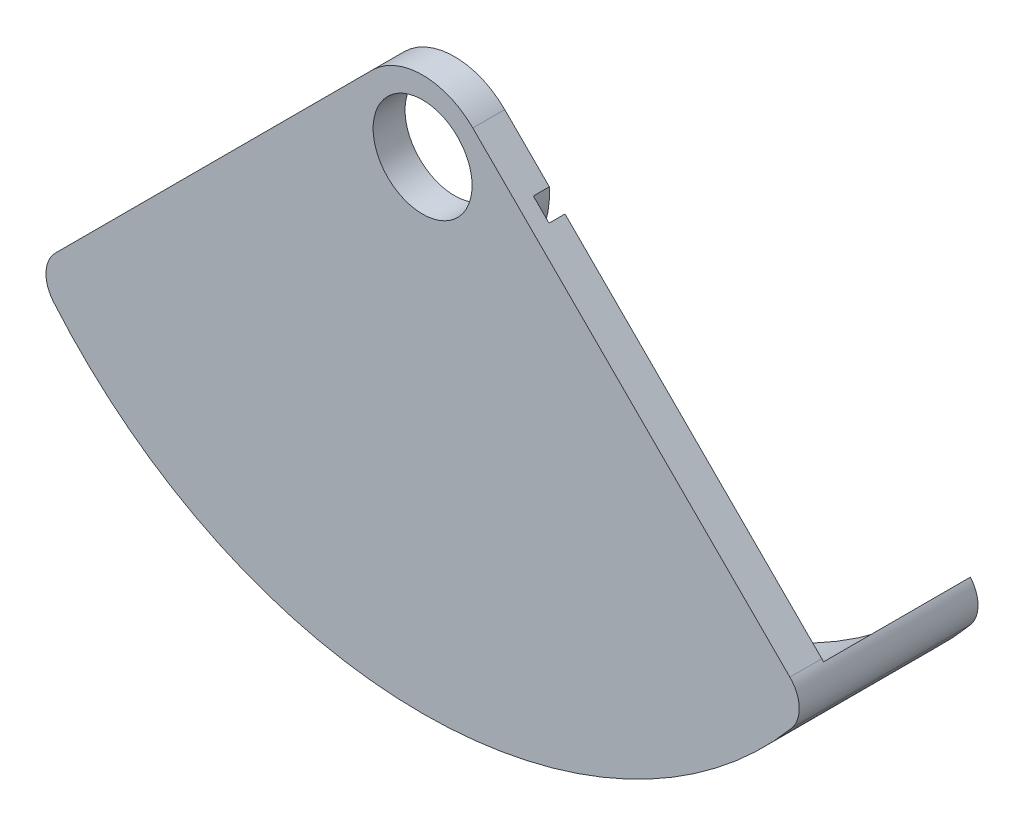
from build123d import *

# Parameters (mm, degrees)
CROQUIS1_R              = 1.55
SALIENTE_EXTRUIR1_DEPTH = 1
CROQUIS3_R              = 1.55
CORTAR_EXTRUIR1_DEPTH   = 0.5
SALIENTE_EXTRUIR2_DEPTH = 4.6


with BuildPart() as part:
    # Croquis1 → Saliente-Extruir1 (new body)
    with BuildSketch(Plane.XY):
        with BuildLine():
            Line((-1.573312588, 1.573312588), (-11.505819195, -8.359194019))
            ThreePointArc((-11.505819195, -8.359194019), (-11.797766675, -9.022819962), (-11.564578543, -9.709300857))
            ThreePointArc((-11.564578543, -9.709300857), (0, -15.1), (11.564578543, -9.709300857))
            ThreePointArc((11.564578543, -9.709300857), (11.797766675, -9.022819962), (11.505819195, -8.359194019))
            Line((11.505819195, -8.359194019), (1.573312588, 1.573312588))
            ThreePointArc((1.573312588, 1.573312588), (0, 2.225), (-1.573312588, 1.573312588))
        make_face()
        Circle(CROQUIS1_R, mode=Mode.SUBTRACT)
    extrude(amount=-SALIENTE_EXTRUIR1_DEPTH)

    # Croquis3 → Cortar-Extruir1 (cut)
    with BuildSketch(Plane(origin=(0, 0, -1), x_dir=(-1, 0, 0), z_dir=(0, 0, -1))):
        Circle(CROQUIS3_R)
        with BuildLine():
            Line((-2.969736593, 0.176888584), (-3.460771197, -0.314146021))
            ThreePointArc((-3.460771197, -0.314146021), (0, -3.475), (3.460771197, -0.314146021))
            Line((3.460771197, -0.314146021), (2.969736593, 0.176888584))
            ThreePointArc((2.969736593, 0.176888584), (0, -2.975), (-2.969736593, 0.176888584))
        make_face()
    extrude(amount=-CORTAR_EXTRUIR1_DEPTH, mode=Mode.SUBTRACT)

    # Croquis4 → Saliente-Extruir2 (add)
    with BuildSketch(Plane(origin=(0, 0, -1), x_dir=(-1, 0, 0), z_dir=(0, 0, -1))):
        with BuildLine():
            ThreePointArc((-11.559897122, -8.41776565), (0, -14.3), (11.559897122, -8.41776565))
            ThreePointArc((11.559897122, -8.41776565), (11.798705845, -9.062676129), (11.564578543, -9.709300857))
            ThreePointArc((11.564578543, -9.709300857), (0, -15.1), (-11.564578543, -9.709300857))
            ThreePointArc((-11.564578543, -9.709300857), (-11.798705845, -9.062676129), (-11.559897122, -8.41776565))
        make_face()
    extrude(amount=SALIENTE_EXTRUIR2_DEPTH)


solid = part.part
